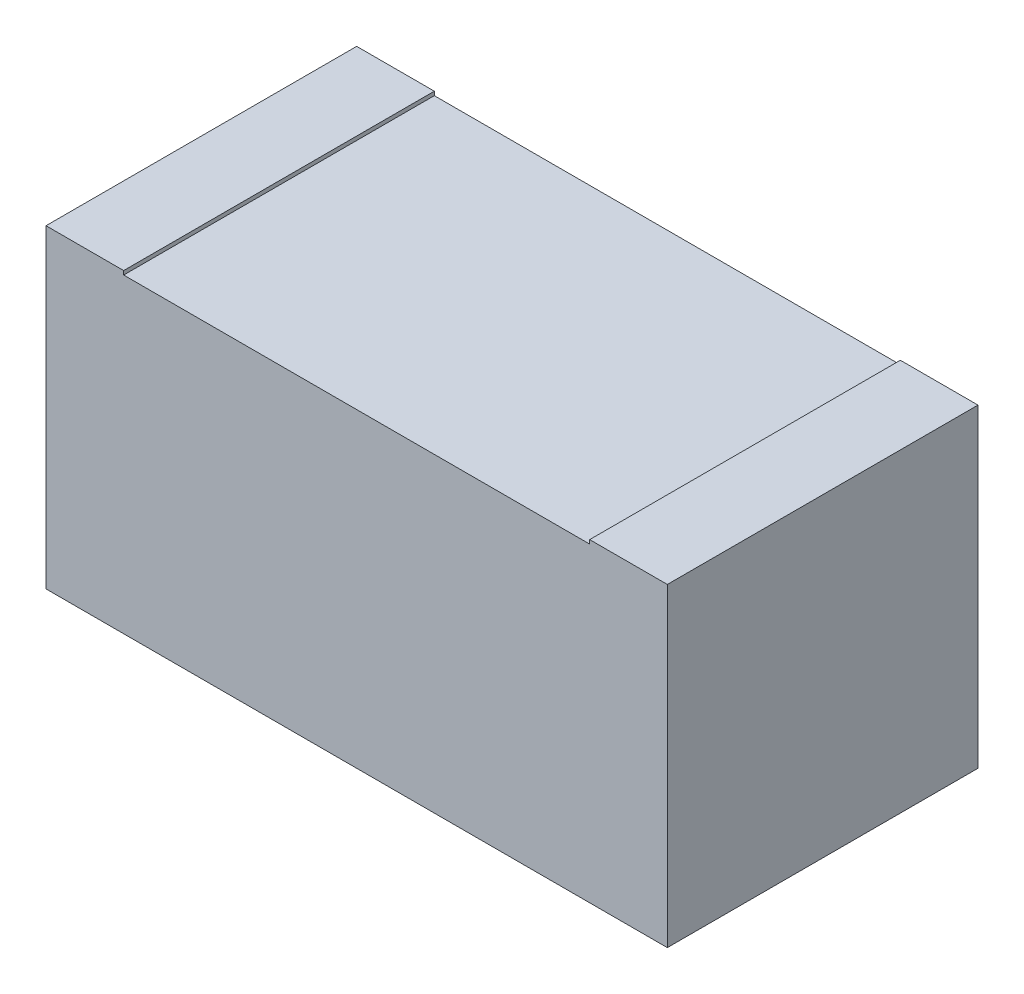
from build123d import *

# Parameters (mm, degrees)
SKETCH_1_W      = 1.6
SKETCH_1_H      = 0.8
EXTRUDE_1_DEPTH = 0.8
SKETCH_2_W      = 0.2
SKETCH_2_H      = 0.8
EXTRUDE_2_DEPTH = 0.01


with BuildPart() as part:
    # Эскиз1 → Бобышка-Вытянуть1 (new body)
    with BuildSketch(Plane(origin=(0, 0, 0), x_dir=(1, 0, 0), z_dir=(0, 1, 0))):
        with Locations((-0.053781513, -0.030252101)):
            Rectangle(SKETCH_1_W, SKETCH_1_H)
    extrude(amount=EXTRUDE_1_DEPTH)

    # Эскиз2 → Бобышка-Вытянуть2 (add)
    with BuildSketch(Plane(origin=(0, 0.8, 0), x_dir=(1, 0, 0), z_dir=(0, 1, 0))):
        with Locations((-0.753781513, -0.030252101)):
            Rectangle(SKETCH_2_W, SKETCH_2_H)
        with Locations((0.646218487, -0.030252101)):
            Rectangle(SKETCH_2_W, SKETCH_2_H)
    extrude(amount=EXTRUDE_2_DEPTH)


solid = part.part
